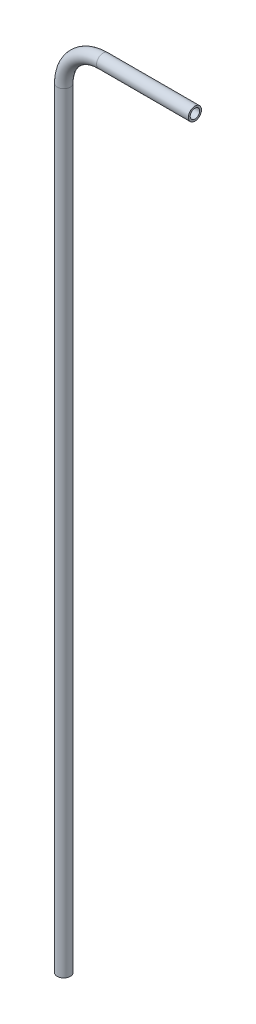
from build123d import *

# Parameters (mm, degrees)
SKETCH2_R   = 3.175
SKETCH2_R_2 = 2.286


with BuildPart() as part:
    # Sweep1: sweep along a path in Sketch1
    with BuildLine(Plane.XY) as sweep1_path:
        Line((0, -374.394317881), (0, -1.522317881))
        ThreePointArc((0, -1.522317881), (5.579615818, 11.948066301), (19.05, 17.527682119))
        Line((19.05, 17.527682119), (63.5, 17.527682119))
    # Sketch2 → Sweep1 (sweep)
    with BuildSketch(Plane(origin=(63.5, 17.527682119, 0), x_dir=(0, 0, -1), z_dir=(1, 0, 0))):
        Circle(SKETCH2_R)
        Circle(SKETCH2_R_2, mode=Mode.SUBTRACT)
    sweep(path=sweep1_path.line)


solid = part.part
